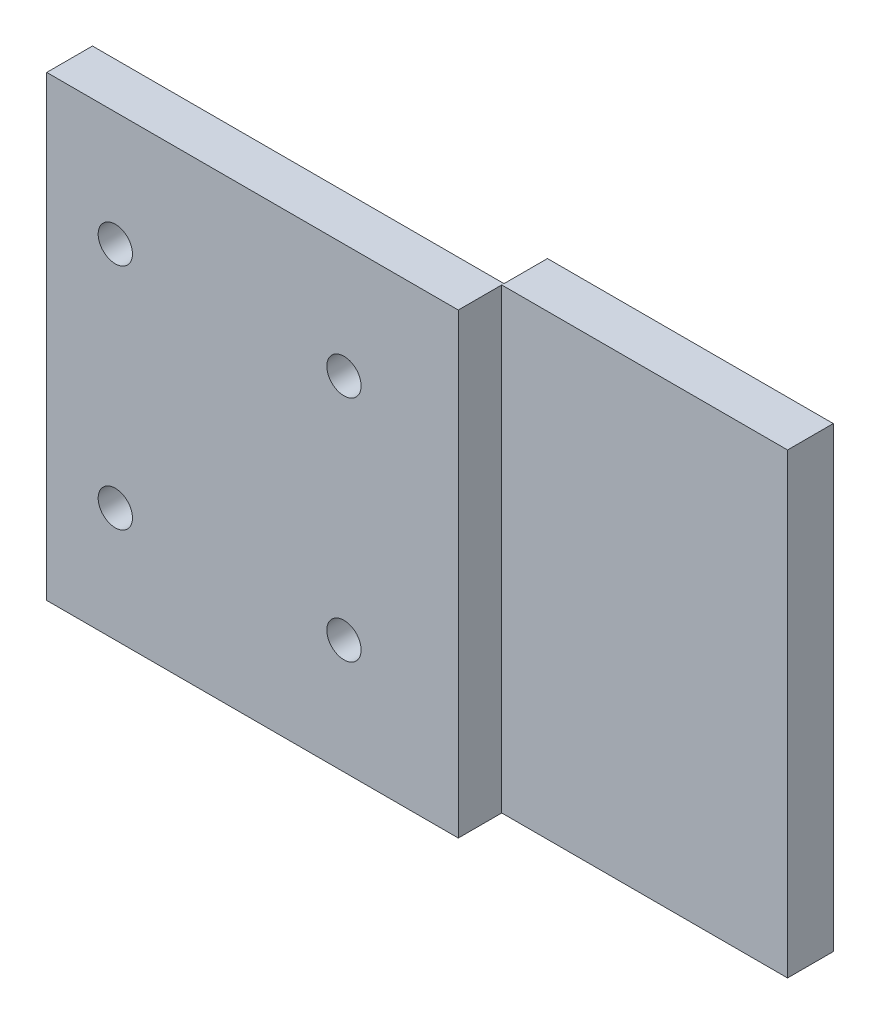
from build123d import *

# Parameters (mm, degrees)
SKETCH_1_W      = 36
SKETCH_1_H      = 40
SKETCH_1_R      = 1.5
EXTRUDE_1_DEPTH = 4
SKETCH_13_W     = 4
SKETCH_13_H     = 40
EXTRUDE_2_DEPTH = 25


with BuildPart() as part:
    # Эскиз1 → Бобышка-Вытянуть1 (new body)
    with BuildSketch(Plane.XY):
        with Locations((18, 20)):
            Rectangle(SKETCH_1_W, SKETCH_1_H)
        with Locations((6, 30)):
            Circle(SKETCH_1_R, mode=Mode.SUBTRACT)
        with Locations((26, 30)):
            Circle(SKETCH_1_R, mode=Mode.SUBTRACT)
        with Locations((26, 10)):
            Circle(SKETCH_1_R, mode=Mode.SUBTRACT)
        with Locations((6, 10)):
            Circle(SKETCH_1_R, mode=Mode.SUBTRACT)
    extrude(amount=EXTRUDE_1_DEPTH)

    # Эскиз13 → Бобышка-Вытянуть2 (add)
    with BuildSketch(Plane(origin=(36, 0, 0), x_dir=(0, 0, -1), z_dir=(1, 0, 0))):
        with Locations((1.8, 20)):
            Rectangle(SKETCH_13_W, SKETCH_13_H)
    extrude(amount=EXTRUDE_2_DEPTH)


solid = part.part
